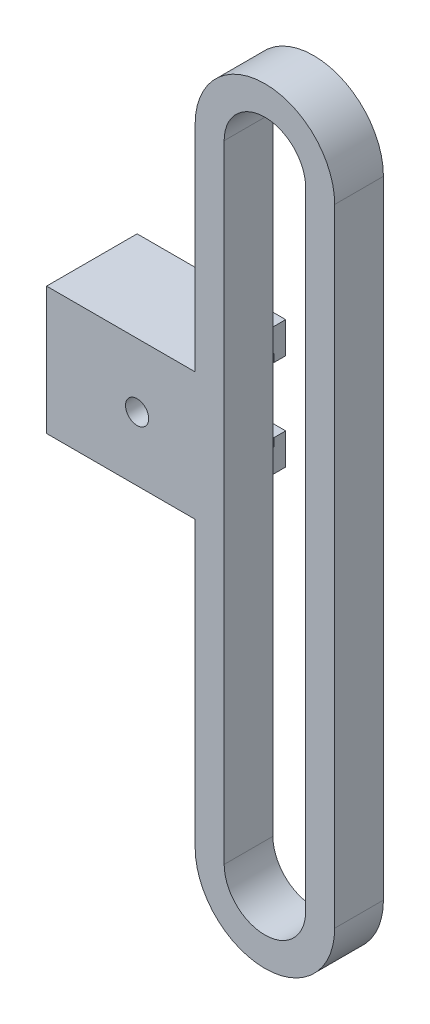
from build123d import *

# Parameters (mm, degrees)
EXTRUDE_1_DEPTH     = 4.2
EXTRUDE_2_DEPTH     = 12.8
SKETCH_3_R          = 1
CUT_EXTRUDE_1_DEPTH = 10
SKETCH_5_W          = 1
SKETCH_5_H          = 2.7
EXTRUDE_3_DEPTH     = 12.8


with BuildPart() as part:
    # 草图1 → 凸台-拉伸1 (new body)
    with BuildSketch(Plane.XY):
        with BuildLine():
            Line((6.01, 10.345093063), (6.01, -43.654906937))
            ThreePointArc((6.01, -43.654906937), (0, -49.664906937), (-6.01, -43.654906937))
            Line((-6.01, -43.654906937), (-6.01, 10.345093063))
            ThreePointArc((-6.01, 10.345093063), (0, 16.355093063), (6.01, 10.345093063))
        make_face()
        with BuildLine():
            Line((3.51, 10.345093063), (3.51, -43.654906937))
            ThreePointArc((3.51, -43.654906937), (0, -47.164906937), (-3.51, -43.654906937))
            Line((-3.51, -43.654906937), (-3.51, 10.345093063))
            ThreePointArc((-3.51, 10.345093063), (0, 13.855093063), (3.51, 10.345093063))
        make_face(mode=Mode.SUBTRACT)
    extrude(amount=EXTRUDE_1_DEPTH)

    # 草图2 → 凸台-拉伸2 (add)
    with BuildSketch(Plane.ZY.offset(6.01)):
        Polygon((4.2, -16.654906937), (4.2, -8.154906937), (-2.6, -8.154906937), (-2.6, -10.154906937), (2.2, -10.154906937), (2.2, -17.154906937), (-2.6, -17.154906937), (-2.6, -19.154906937), (4.2, -19.154906937), align=None)
    extrude(amount=EXTRUDE_2_DEPTH)

    # 草图3 → 切除-拉伸1 (cut)
    with BuildSketch(Plane(origin=(0, 0, 2.2), x_dir=(-1, 0, 0), z_dir=(0, 0, -1))):
        with Locations((11.01, -13.654906937)):
            Circle(SKETCH_3_R)
    extrude(amount=-CUT_EXTRUDE_1_DEPTH, mode=Mode.SUBTRACT)

    # 草图5 → 凸台-拉伸3 (add, through all)
    with BuildSketch(Plane(origin=(-6.01, 0, 0), x_dir=(0, 0, -1), z_dir=(1, 0, 0))):
        with Locations((3.1, -9.504906937)):
            Rectangle(SKETCH_5_W, SKETCH_5_H)
        with Locations((3.1, -17.804906937)):
            Rectangle(SKETCH_5_W, SKETCH_5_H)
    extrude(amount=-EXTRUDE_3_DEPTH)


solid = part.part
